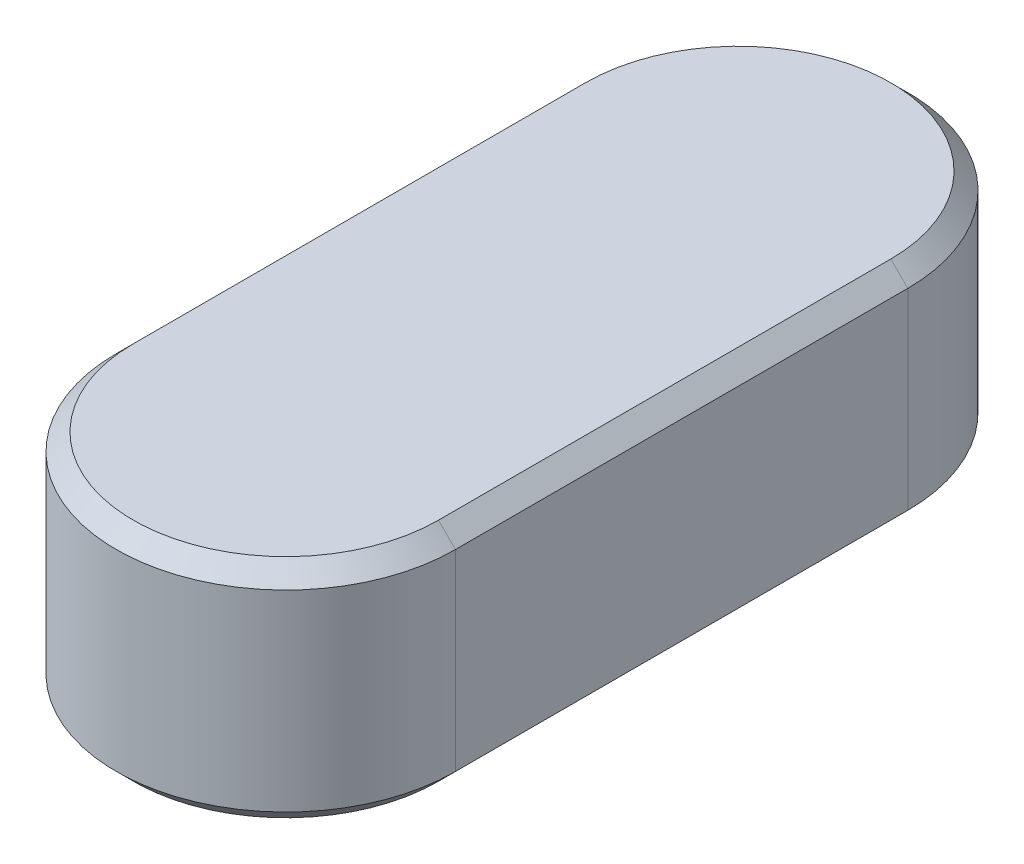
from build123d import *

# Parameters (mm, degrees)
BOSS_EXTRUDE1_DEPTH = 8
CHAMFER1_SIZE       = 0.6


with BuildPart() as part:
    # Sketch1 → Boss-Extrude1 (new body)
    with BuildSketch(Plane(origin=(0, 0, 0), x_dir=(1, 0, 0), z_dir=(0, 1, 0))):
        with BuildLine():
            Line((6, 0), (6, 16))
            ThreePointArc((6, 16), (0, 22), (-6, 16))
            Line((-6, 16), (-6, 0))
            ThreePointArc((-6, 0), (0, -6), (6, 0))
        make_face()
    extrude(amount=BOSS_EXTRUDE1_DEPTH)

    # Chamfer1
    chamfer1_edges = [part.edges().sort_by_distance(p)[0] for p in [
        (0, 8, -22),
        (-6, 8, -8),
        (0, 8, 6),
        (-6, 0, -8),
        (0, 0, -22),
        (6, 0, -8),
        (0, 0, 6),
        (6, 8, -8),
    ]]
    chamfer(chamfer1_edges, length=CHAMFER1_SIZE)


solid = part.part
